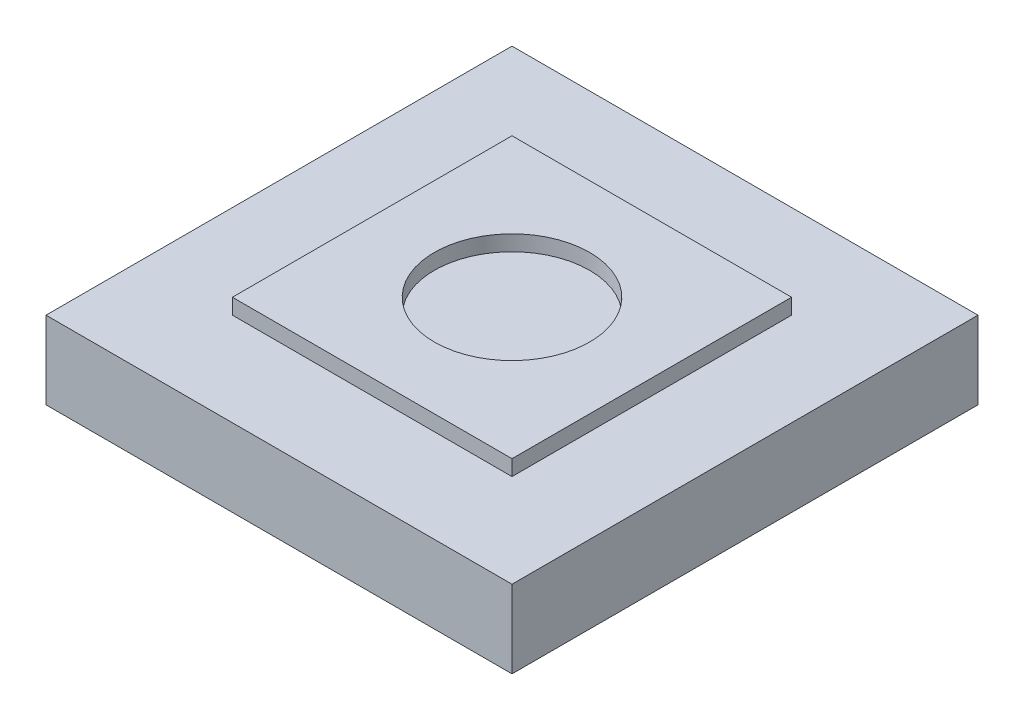
from build123d import *

# Parameters (mm, degrees)
SKETCH1_W           = 15.24
SKETCH1_H           = 15.24
BOSS_EXTRUDE1_DEPTH = 2.54
SKETCH2_W           = 9.144
SKETCH2_H           = 9.144
BOSS_EXTRUDE2_DEPTH = 3.048
SKETCH3_R           = 2.54
CUT_EXTRUDE1_DEPTH  = 0.508


with BuildPart() as part:
    # Sketch1 → Boss-Extrude1 (new body)
    with BuildSketch(Plane(origin=(0, 0, 0), x_dir=(1, 0, 0), z_dir=(0, 1, 0))):
        with Locations((7.62, 7.62)):
            Rectangle(SKETCH1_W, SKETCH1_H)
    extrude(amount=BOSS_EXTRUDE1_DEPTH)

    # Sketch2 → Boss-Extrude2 (add)
    with BuildSketch(Plane(origin=(0, 0, 0), x_dir=(1, 0, 0), z_dir=(0, 1, 0))):
        with Locations((7.62, 7.62)):
            Rectangle(SKETCH2_W, SKETCH2_H)
    extrude(amount=BOSS_EXTRUDE2_DEPTH)

    # Sketch3 → Cut-Extrude1 (cut)
    with BuildSketch(Plane(origin=(0, 3.048, 0), x_dir=(1, 0, 0), z_dir=(0, 1, 0))):
        with Locations((7.62, 7.62)):
            Circle(SKETCH3_R)
    extrude(amount=-CUT_EXTRUDE1_DEPTH, mode=Mode.SUBTRACT)


solid = part.part
